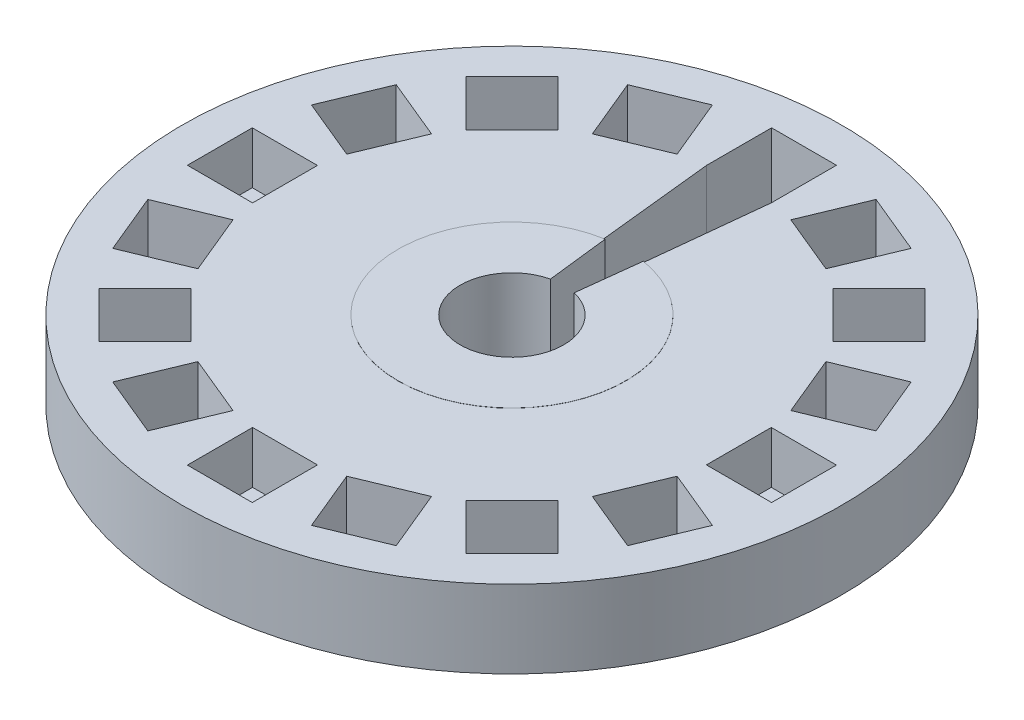
from build123d import *

# Parameters (mm, degrees)
SKETCH1_R                = 63.5
BOSS_EXTRUDE1_DEPTH      = 14.973360437
SKETCH2_W                = 12.5
SKETCH2_H                = 12.56
CUT_EXTRUDE1_DEPTH       = 10
CIRPATTERN1_COUNT        = 16
SKETCH5_W                = 12.5
SKETCH5_H                = 12.56
CUT_EXTRUDE3_DEPTH       = 37
CUT_EXTRUDE3_DEPTH_BACK  = 31
SKETCH6_R                = 17.625930659
CUT_EXTRUDE4_DEPTH       = 26
CUT_EXTRUDE4_DEPTH_BACK  = 37
CUT_EXTRUDE9_DEPTH       = 19
CUT_EXTRUDE9_DEPTH_BACK  = 11
SKETCH13_R               = 21.952850423
BOSS_EXTRUDE4_DEPTH      = 15
BOSS_EXTRUDE4_DEPTH_BACK = 18
SKETCH16_R               = 9.976383377
CUT_EXTRUDE11_DEPTH      = 33
CUT_EXTRUDE11_DEPTH_BACK = 29
CUT_EXTRUDE15_DEPTH      = 27
CUT_EXTRUDE15_DEPTH_BACK = 29


with BuildPart() as part:
    # Sketch1 → Boss-Extrude1 (new body)
    with BuildSketch(Plane(origin=(0, 0, 0), x_dir=(1, 0, 0), z_dir=(0, 1, 0))):
        Circle(SKETCH1_R)
    extrude(amount=BOSS_EXTRUDE1_DEPTH)

    # Sketch2 → Cut-Extrude1 (cut)
    with BuildSketch(Plane(origin=(0, 14.973360437, 0), x_dir=(1, 0, 0), z_dir=(0, 1, 0))):
        with Locations((0, -50)):
            Rectangle(SKETCH2_W, SKETCH2_H)
    cut_extrude1 = extrude(amount=-CUT_EXTRUDE1_DEPTH, mode=Mode.SUBTRACT)

    # CirPattern1: Cut-Extrude1 ×16 about axis
    cirpattern1_axis = Axis((0, 0, 0), (0, 1, 0))
    for i in range(1, CIRPATTERN1_COUNT):
        add(cut_extrude1.rotate(cirpattern1_axis, i * 360 / CIRPATTERN1_COUNT), mode=Mode.SUBTRACT)

    # Sketch5 → Cut-Extrude3 (cut, two sides)
    with BuildSketch(Plane(origin=(0, 0, 0), x_dir=(1, 0, 0), z_dir=(0, 1, 0))) as cut_extrude3_sk:
        with Locations((0, 50)):
            Rectangle(SKETCH5_W, SKETCH5_H)
    extrude(amount=CUT_EXTRUDE3_DEPTH, mode=Mode.SUBTRACT)
    extrude(cut_extrude3_sk.sketch, amount=-CUT_EXTRUDE3_DEPTH_BACK, mode=Mode.SUBTRACT)

    # Sketch6 → Cut-Extrude4 (cut, two sides)
    with BuildSketch(Plane(origin=(0, 14.973360437, 0), x_dir=(1, 0, 0), z_dir=(0, 1, 0))) as cut_extrude4_sk:
        Circle(SKETCH6_R)
    extrude(amount=CUT_EXTRUDE4_DEPTH, mode=Mode.SUBTRACT)
    extrude(cut_extrude4_sk.sketch, amount=-CUT_EXTRUDE4_DEPTH_BACK, mode=Mode.SUBTRACT)

    # Sketch9 → Cut-Extrude9 (cut, two sides)
    with BuildSketch(Plane(origin=(0, 0, 0), x_dir=(1, 0, 0), z_dir=(0, 1, 0))) as cut_extrude9_sk:
        Polygon((-6.25, 43.72), (0, -15.098638444), (6.25, 43.72), align=None)
    extrude(amount=CUT_EXTRUDE9_DEPTH, mode=Mode.SUBTRACT)
    extrude(cut_extrude9_sk.sketch, amount=-CUT_EXTRUDE9_DEPTH_BACK, mode=Mode.SUBTRACT)

    # Sketch13 → Boss-Extrude4 (add, two sides)
    with BuildSketch(Plane(origin=(0, 0, 0), x_dir=(1, 0, 0), z_dir=(0, 1, 0))) as boss_extrude4_sk:
        Circle(SKETCH13_R)
    extrude(amount=BOSS_EXTRUDE4_DEPTH)
    extrude(boss_extrude4_sk.sketch, amount=-BOSS_EXTRUDE4_DEPTH_BACK)

    # Sketch16 → Cut-Extrude11 (cut, two sides)
    with BuildSketch(Plane(origin=(0, 0, 0), x_dir=(1, 0, 0), z_dir=(0, 1, 0))) as cut_extrude11_sk:
        Circle(SKETCH16_R)
    extrude(amount=CUT_EXTRUDE11_DEPTH, mode=Mode.SUBTRACT)
    extrude(cut_extrude11_sk.sketch, amount=-CUT_EXTRUDE11_DEPTH_BACK, mode=Mode.SUBTRACT)

    # Sketch17 → Cut-Extrude15 (cut, two sides)
    with BuildSketch(Plane(origin=(0, 0, 0), x_dir=(1, 0, 0), z_dir=(0, 1, 0))) as cut_extrude15_sk:
        Polygon((-6.25, 43.72), (0, -9.976383377), (6.25, 43.72), align=None)
    extrude(amount=CUT_EXTRUDE15_DEPTH, mode=Mode.SUBTRACT)
    extrude(cut_extrude15_sk.sketch, amount=-CUT_EXTRUDE15_DEPTH_BACK, mode=Mode.SUBTRACT)


solid = part.part
